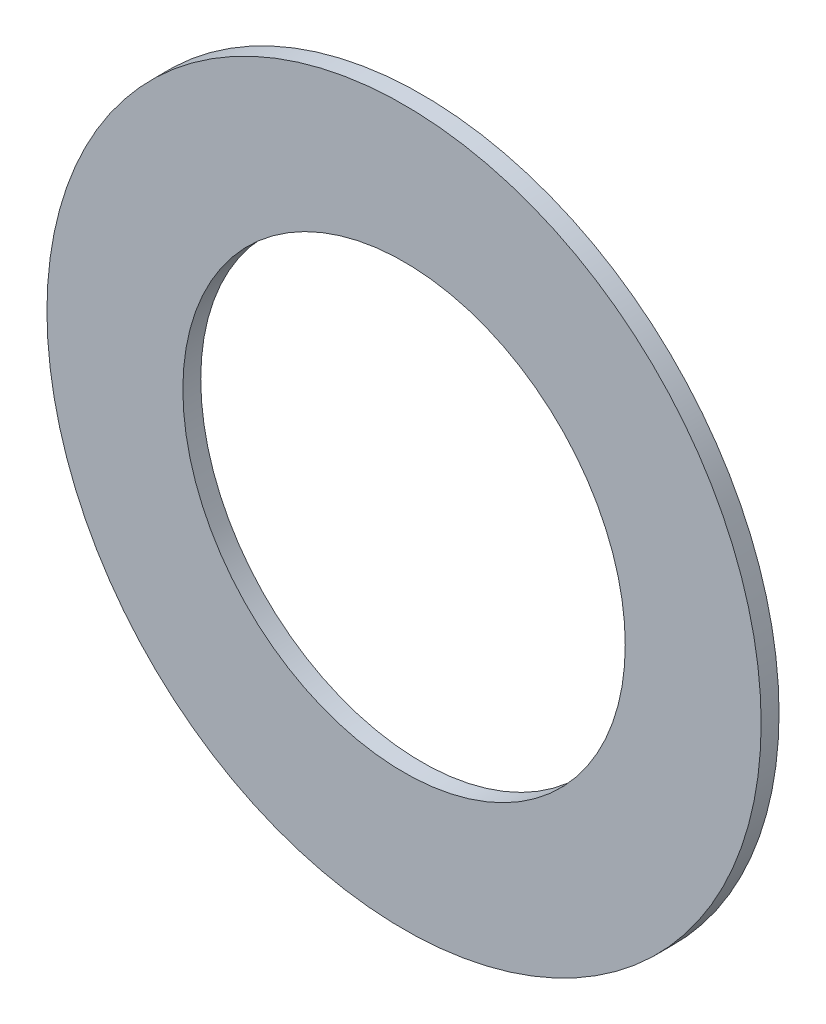
from build123d import *

# Parameters (mm, degrees)
SKETCH1_R           = 63.373
SKETCH1_R_2         = 39.2557
BOSS_EXTRUDE1_DEPTH = 3.175


with BuildPart() as part:
    # Sketch1 → Boss-Extrude1 (new body)
    with BuildSketch(Plane.XY):
        Circle(SKETCH1_R)
        Circle(SKETCH1_R_2, mode=Mode.SUBTRACT)
    extrude(amount=BOSS_EXTRUDE1_DEPTH)


solid = part.part
